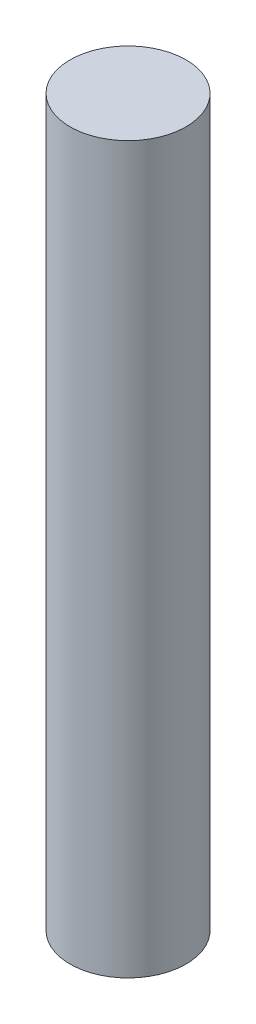
from build123d import *


with BuildPart() as part:
    # Esquisse1 → Révolution1 (revolve)
    with BuildSketch(Plane.XY):
        Polygon((2.5, 0), (4, 0), (4, 50), (0, 50), (0, 10), (2.5, 10), align=None)
    revolve(axis=Axis((0, 10, 0), (0, 1, 0)))


solid = part.part
